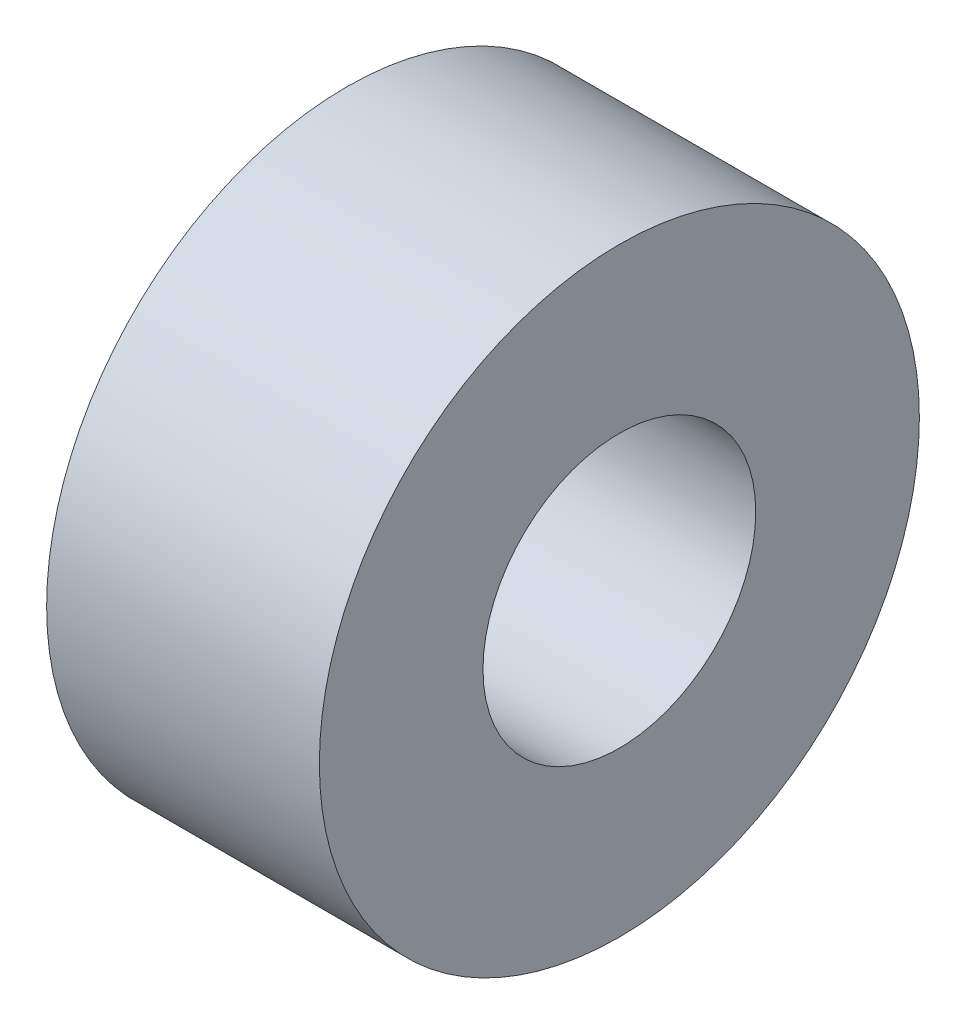
from build123d import *

# Parameters (mm, degrees)
SKETCH1_R           = 8.73125
SKETCH1_R_2         = 3.96875
BOSS_EXTRUDE1_DEPTH = 3.96875


with BuildPart() as part:
    # Sketch1 → Boss-Extrude1 (new body, symmetric)
    with BuildSketch(Plane(origin=(0, 0, 0), x_dir=(0, 0, -1), z_dir=(1, 0, 0))):
        Circle(SKETCH1_R)
        Circle(SKETCH1_R_2, mode=Mode.SUBTRACT)
    extrude(amount=BOSS_EXTRUDE1_DEPTH, both=True)


solid = part.part
